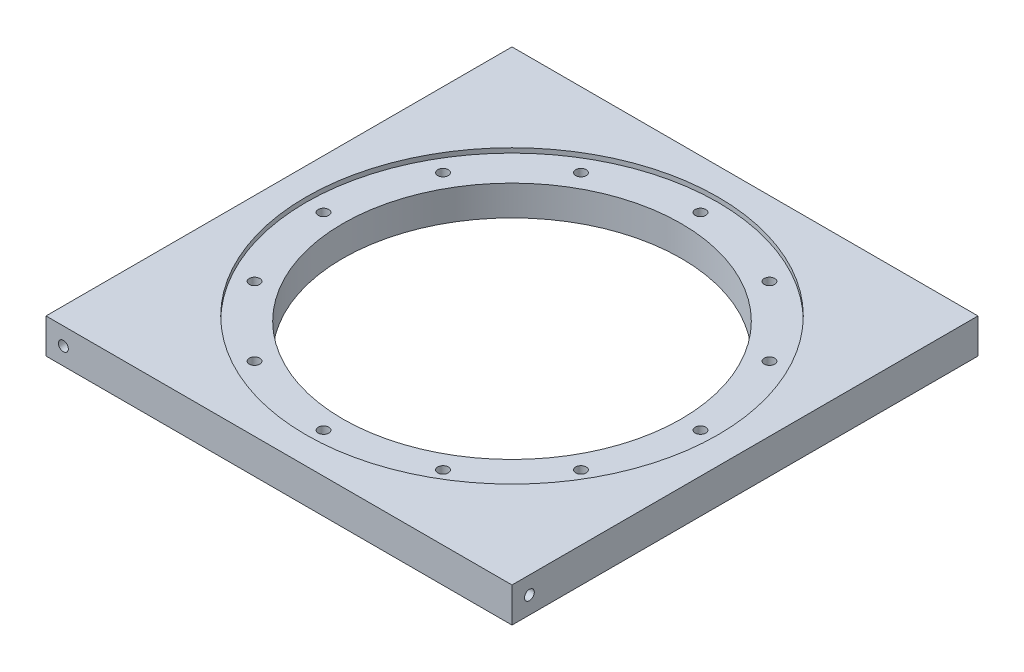
from build123d import *

# Parameters (mm, degrees)
SKETCH1_W           = 127.635
SKETCH1_H           = 127.635
BOSS_EXTRUDE1_DEPTH = 9.525
SKETCH6_R           = 1.35255
F_6_32_HOLE1_DEPTH  = 12.7
SKETCH7_R           = 1.35255
F_6_32_HOLE2_DEPTH  = 12.7
SKETCH8_R           = 1.35255
F_6_32_HOLE3_DEPTH  = 12.7
SKETCH9_R           = 1.35255
F_6_32_HOLE4_DEPTH  = 12.7
SKETCH5_R           = 46.355
CUT_EXTRUDE1_DEPTH  = 9.525
SKETCH11_R          = 1.4351
CUT_EXTRUDE3_DEPTH  = 10.525
CIRPATTERN1_COUNT   = 12
SKETCH12_R          = 56.41975
CUT_EXTRUDE4_DEPTH  = 1.27


with BuildPart() as part:
    # Sketch1 → Boss-Extrude1 (new body)
    with BuildSketch(Plane(origin=(0, 0, 0), x_dir=(1, 0, 0), z_dir=(0, 1, 0))):
        with Locations((63.8175, 63.8175)):
            Rectangle(SKETCH1_W, SKETCH1_H)
    extrude(amount=BOSS_EXTRUDE1_DEPTH)

    # Sketch6 → 6-32 hole1 (cut)
    with BuildSketch(Plane(origin=(127.635, 0, 0), x_dir=(0, 0, -1), z_dir=(1, 0, 0))):
        with Locations((4.7625, 4.7625)):
            Circle(SKETCH6_R)
    extrude(amount=-F_6_32_HOLE1_DEPTH, mode=Mode.SUBTRACT)

    # Sketch7 → 6-32 hole2 (cut)
    with BuildSketch(Plane(origin=(0, 0, -127.635), x_dir=(-1, 0, 0), z_dir=(0, 0, -1))):
        with Locations((-122.8725, 4.7625)):
            Circle(SKETCH7_R)
    extrude(amount=-F_6_32_HOLE2_DEPTH, mode=Mode.SUBTRACT)

    # Sketch8 → 6-32 hole3 (cut)
    with BuildSketch(Plane.ZY):
        with Locations((-122.8725, 4.7625)):
            Circle(SKETCH8_R)
    extrude(amount=-F_6_32_HOLE3_DEPTH, mode=Mode.SUBTRACT)

    # Sketch9 → 6-32 hole4 (cut)
    with BuildSketch(Plane.XY):
        with Locations((4.7625, 4.7625)):
            Circle(SKETCH9_R)
    extrude(amount=-F_6_32_HOLE4_DEPTH, mode=Mode.SUBTRACT)

    # Sketch5 → Cut-Extrude1 (cut)
    with BuildSketch(Plane(origin=(0, 9.525, 0), x_dir=(1, 0, 0), z_dir=(0, 1, 0))):
        with Locations((63.8175, 63.8175)):
            Circle(SKETCH5_R)
    extrude(amount=-CUT_EXTRUDE1_DEPTH, mode=Mode.SUBTRACT)

    # Sketch11 → Cut-Extrude3 (cut, through all)
    with BuildSketch(Plane(origin=(0, 9.525, 0), x_dir=(1, 0, 0), z_dir=(0, 1, 0))):
        with Locations((63.8175, 115.443)):
            Circle(SKETCH11_R)
    cut_extrude3 = extrude(amount=-CUT_EXTRUDE3_DEPTH, mode=Mode.SUBTRACT)

    # CirPattern1: Cut-Extrude3 ×12 about axis
    cirpattern1_axis = Axis((63.8175, 0, -63.8175), (0, 1, 0))
    for i in range(1, CIRPATTERN1_COUNT):
        add(cut_extrude3.rotate(cirpattern1_axis, i * 360 / CIRPATTERN1_COUNT), mode=Mode.SUBTRACT)

    # Sketch12 → Cut-Extrude4 (cut)
    with BuildSketch(Plane(origin=(0, 9.525, 0), x_dir=(1, 0, 0), z_dir=(0, 1, 0))):
        with Locations((63.8175, 63.8175)):
            Circle(SKETCH12_R)
    extrude(amount=-CUT_EXTRUDE4_DEPTH, mode=Mode.SUBTRACT)


solid = part.part
